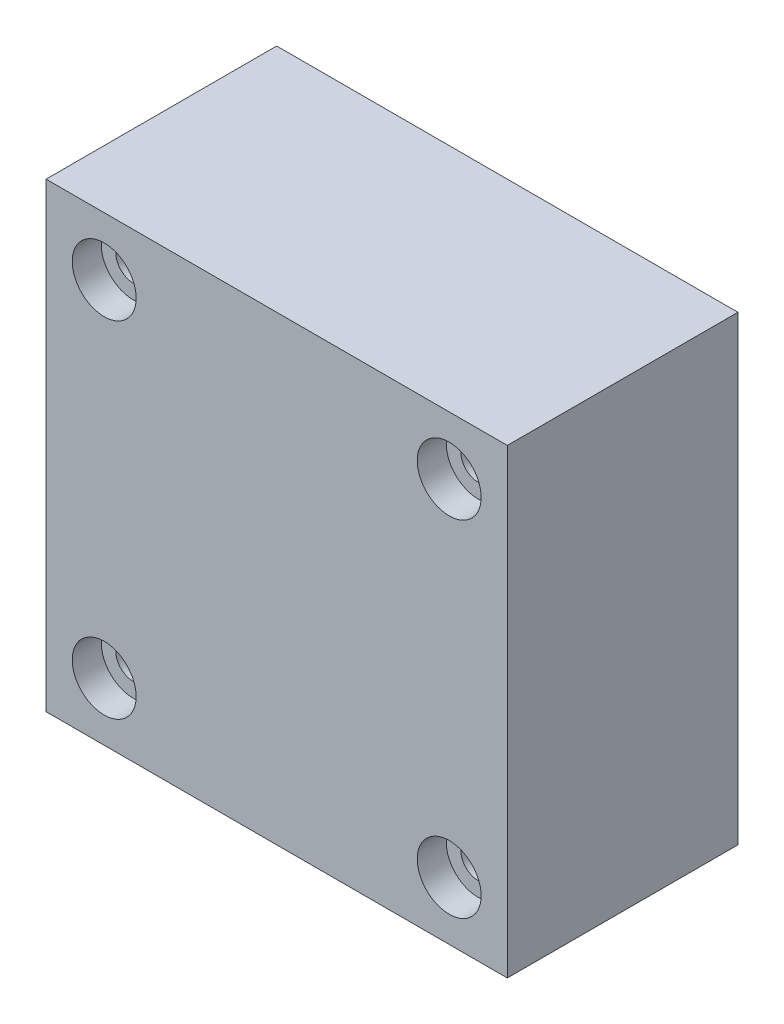
from build123d import *

# Parameters (mm, degrees)
SKETCH1_W                      = 31.75
SKETCH1_H                      = 31.75
BOSS_EXTRUDE1_DEPTH            = 7.9375
CBORE_FOR_M2_SHCS1_D           = 2.4
CBORE_FOR_M2_SHCS1_CBORE_D     = 4.4
CBORE_FOR_M2_SHCS1_CBORE_DEPTH = 2


with BuildPart() as part:
    # Sketch1 → Boss-Extrude1 (new body, symmetric)
    with BuildSketch(Plane.XY):
        Rectangle(SKETCH1_W, SKETCH1_H)
    extrude(amount=BOSS_EXTRUDE1_DEPTH, both=True)

    # CBORE for M2 SHCS1 (through all)
    with Locations(Plane.XY.offset(7.9375)):
        with Locations((-11.875, 11.875), (11.875, 11.875), (11.875, -11.875), (-11.875, -11.875)):
            CounterBoreHole(CBORE_FOR_M2_SHCS1_D / 2, CBORE_FOR_M2_SHCS1_CBORE_D / 2, CBORE_FOR_M2_SHCS1_CBORE_DEPTH)


solid = part.part
